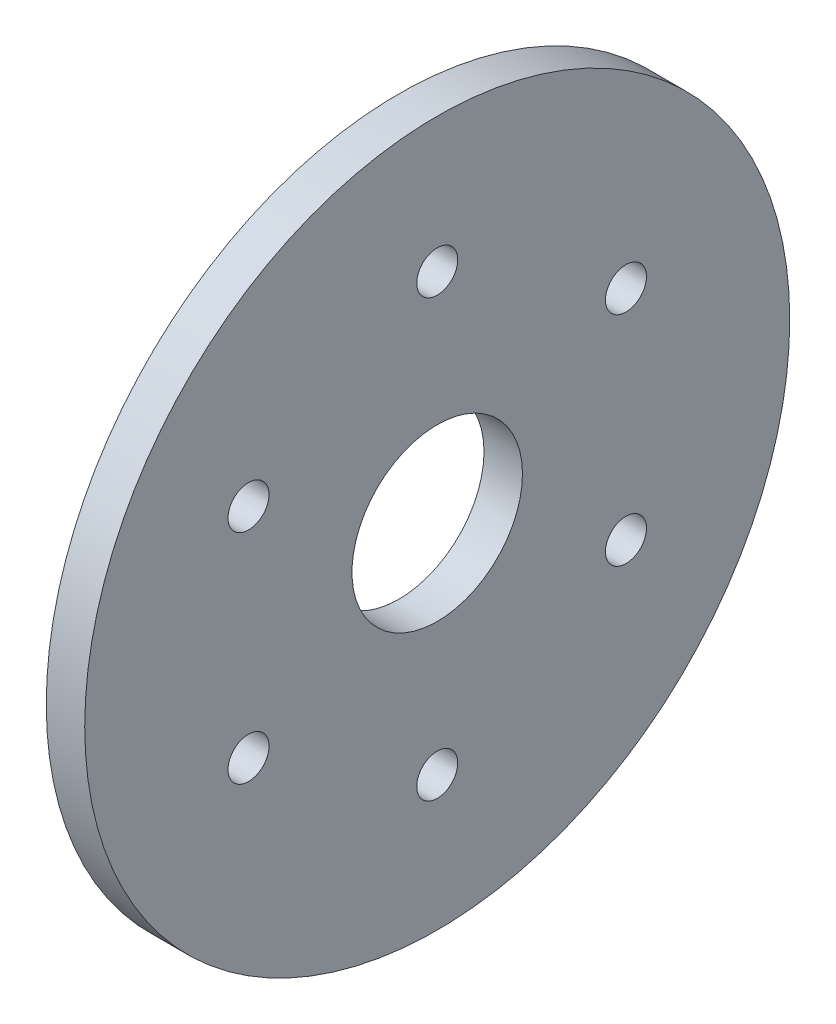
from build123d import *

# Parameters (mm, degrees)
SKETCH1_R           = 27.5
SKETCH1_R_2         = 6.65
BOSS_EXTRUDE1_DEPTH = 3
SKETCH3_R           = 1.6
CUT_EXTRUDE1_DEPTH  = 4


with BuildPart() as part:
    # Sketch1 → Boss-Extrude1 (new body)
    with BuildSketch(Plane(origin=(0, 0, 0), x_dir=(0, 0, -1), z_dir=(1, 0, 0))):
        Circle(SKETCH1_R)
        Circle(SKETCH1_R_2, mode=Mode.SUBTRACT)
    extrude(amount=BOSS_EXTRUDE1_DEPTH)

    # Sketch3 → Cut-Extrude1 (cut, through all)
    with BuildSketch(Plane(origin=(3, 0, 0), x_dir=(0, 0, -1), z_dir=(1, 0, 0))):
        with Locations((0, 17)):
            Circle(SKETCH3_R)
        with Locations((14.722431864, 8.5)):
            Circle(SKETCH3_R)
        with Locations((14.722431864, -8.5)):
            Circle(SKETCH3_R)
        with Locations((0, -17)):
            Circle(SKETCH3_R)
        with Locations((-14.722431864, -8.5)):
            Circle(SKETCH3_R)
        with Locations((-14.722431864, 8.5)):
            Circle(SKETCH3_R)
    extrude(amount=-CUT_EXTRUDE1_DEPTH, mode=Mode.SUBTRACT)


solid = part.part
